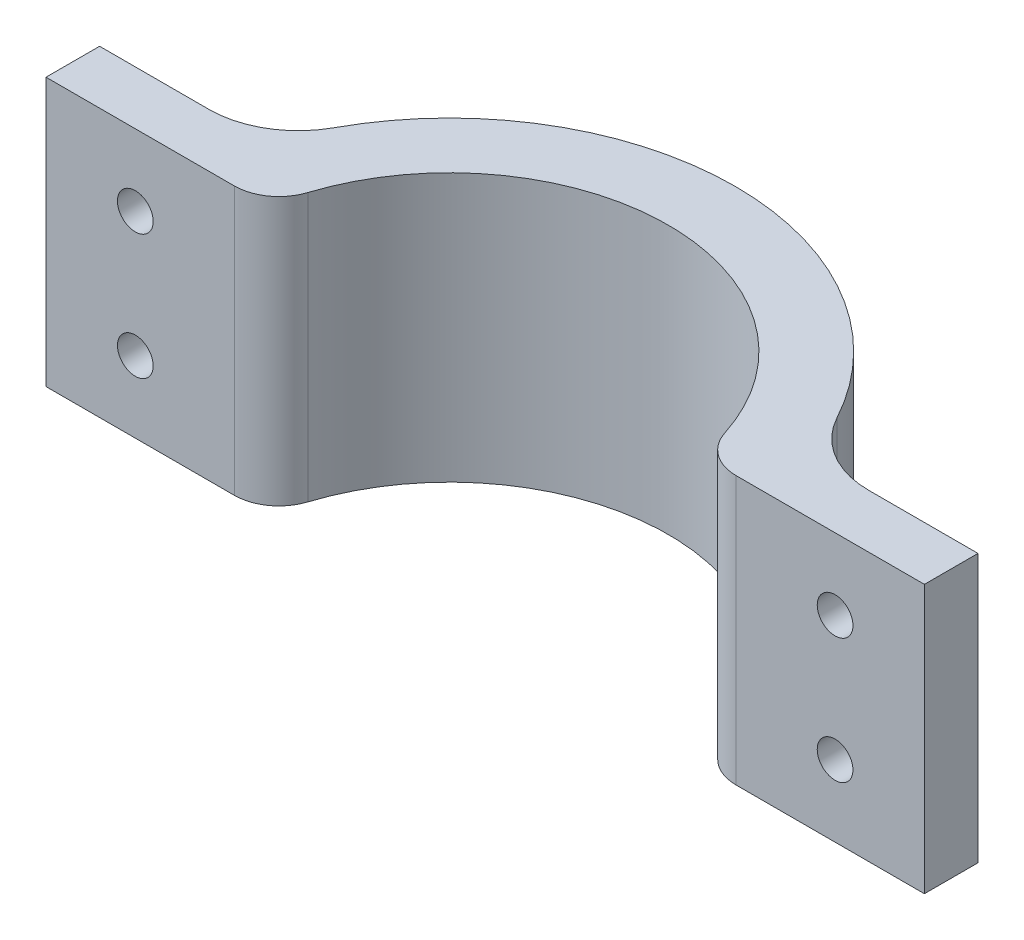
from build123d import *

# Parameters (mm, degrees)
BOSS_EXTRUDE1_DEPTH = 30
SKETCH2_R           = 2
CUT_EXTRUDE1_DEPTH  = 7
FILLET1_R           = 10
FILLET2_R           = 5


with BuildPart() as part:
    # Sketch1 → Boss-Extrude1 (new body)
    with BuildSketch(Plane(origin=(0, 0, 0), x_dir=(1, 0, 0), z_dir=(0, 1, 0))):
        with BuildLine():
            ThreePointArc((-24.171263931, 4), (0, 24.5), (24.171263931, 4))
            Line((24.171263931, 4), (49.171263931, 4))
            Line((49.171263931, 4), (49.171263931, 10))
            Line((49.171263931, 10), (30.397368307, 10))
            ThreePointArc((30.397368307, 10), (0, 32), (-30.397368307, 10))
            Line((-30.397368307, 10), (-49.171263931, 10))
            Line((-49.171263931, 10), (-49.171263931, 4))
            Line((-49.171263931, 4), (-24.171263931, 4))
        make_face()
    extrude(amount=BOSS_EXTRUDE1_DEPTH)

    # Sketch2 → Cut-Extrude1 (cut, through all)
    with BuildSketch(Plane(origin=(0, 0, -10), x_dir=(-1, 0, 0), z_dir=(0, 0, -1))):
        with Locations((-39.171263931, 22)):
            Circle(SKETCH2_R)
        with Locations((-39.171263931, 8)):
            Circle(SKETCH2_R)
        with Locations((39.171263931, 8)):
            Circle(SKETCH2_R)
        with Locations((39.171263931, 22)):
            Circle(SKETCH2_R)
    extrude(amount=-CUT_EXTRUDE1_DEPTH, mode=Mode.SUBTRACT)

    # Fillet1
    fillet1_edges = [part.edges().sort_by_distance(p)[0] for p in [
        (-30.397368307, 15, -10),
        (30.397368307, 15, -10),
    ]]
    fillet(fillet1_edges, radius=FILLET1_R)

    # Fillet2
    fillet2_edges = [part.edges().sort_by_distance(p)[0] for p in [
        (-24.171263931, 15, -4),
        (24.171263931, 15, -4),
    ]]
    fillet(fillet2_edges, radius=FILLET2_R)


solid = part.part
